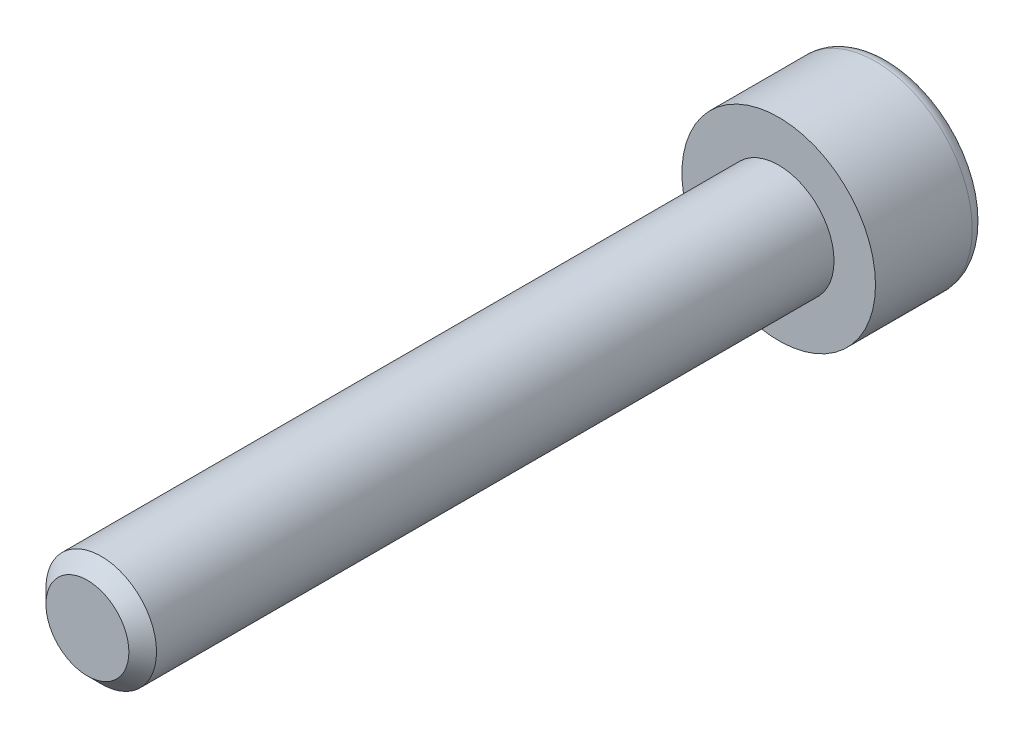
from build123d import *

# Parameters (mm, degrees)
ESQUISSE1_R             = 3.5
BOSS_EXTRU_1_DEPTH      = 4
ESQUISSE2_R             = 2
BOSS_EXTRU_2_DEPTH      = 25
ENL_V_MAT_EXTRU_1_DEPTH = 3
CHANFREIN1_SIZE         = 0.5
CONG_1_R                = 0.5


with BuildPart() as part:
    # Esquisse1 → Boss.-Extru.1 (new body)
    with BuildSketch(Plane.XY):
        Circle(ESQUISSE1_R)
    extrude(amount=BOSS_EXTRU_1_DEPTH)

    # Esquisse2 → Boss.-Extru.2 (add)
    with BuildSketch(Plane.XY.offset(4)):
        Circle(ESQUISSE2_R)
    extrude(amount=BOSS_EXTRU_2_DEPTH)

    # Esquisse3 → Enlèv. mat.-Extru.1 (cut)
    with BuildSketch(Plane(origin=(0, 0, 0), x_dir=(-1, 0, 0), z_dir=(0, 0, -1))):
        Polygon((1.732050808, 0), (0.866025404, 1.5), (-0.866025404, 1.5), (-1.732050808, 0), (-0.866025404, -1.5), (0.866025404, -1.5), align=None)
    extrude(amount=-ENL_V_MAT_EXTRU_1_DEPTH, mode=Mode.SUBTRACT)

    # Chanfrein1
    chanfrein1_edges = [part.edges().sort_by_distance(p)[0] for p in [
        (-2, 0, 29),
    ]]
    chamfer(chanfrein1_edges, length=CHANFREIN1_SIZE)

    # Congé1
    cong_1_edges = [part.edges().sort_by_distance(p)[0] for p in [
        (-3.5, 0, 0),
    ]]
    fillet(cong_1_edges, radius=CONG_1_R)


solid = part.part
